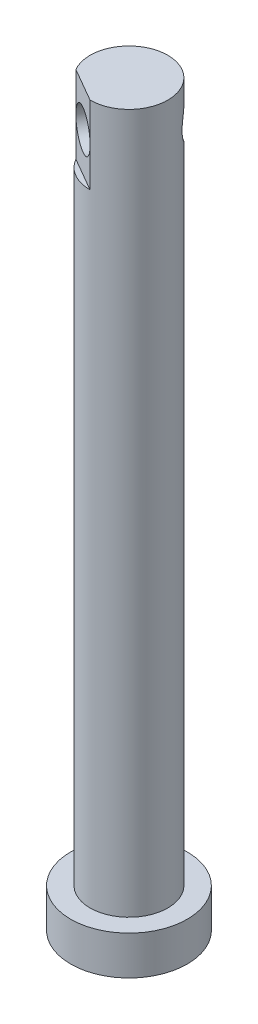
from build123d import *

# Parameters (mm, degrees)
SKETCH_1_R          = 7.5
EXTRUDE_1_DEPTH     = 5
SKETCH_2_R          = 5
EXTRUDE_2_DEPTH     = 90
CUT_EXTRUDE_1_DEPTH = 10
SKETCH_13_R         = 2.500883101
CUT_EXTRUDE_2_DEPTH = 10


with BuildPart() as part:
    # Эскиз1 → Бобышка-Вытянуть1 (new body)
    with BuildSketch(Plane(origin=(0, 0, 0), x_dir=(1, 0, 0), z_dir=(0, 1, 0))):
        with Locations((40.81014851, -30.211534636)):
            Circle(SKETCH_1_R)
    extrude(amount=EXTRUDE_1_DEPTH)

    # Эскиз2 → Бобышка-Вытянуть2 (add)
    with BuildSketch(Plane(origin=(0, 5, 0), x_dir=(1, 0, 0), z_dir=(0, 1, 0))):
        with Locations((40.81014851, -30.211534636)):
            Circle(SKETCH_2_R)
    extrude(amount=EXTRUDE_2_DEPTH)

    # Эскиз12 → Вырез-Вытянуть1 (cut)
    with BuildSketch(Plane(origin=(0, 95, 0), x_dir=(1, 0, 0), z_dir=(0, 1, 0))):
        Polygon((40.81014851, -35.211534636), (36.479002075, -32.709768123), (36.139784444, -33.297033651), (40.47093088, -35.798800164), align=None)
    extrude(amount=-CUT_EXTRUDE_1_DEPTH, mode=Mode.SUBTRACT)

    # Эскиз13 → Вырез-Вытянуть2 (cut)
    with BuildSketch(Plane(origin=(-5.040884978, 0, 8.726957886), x_dir=(0.865923408, 0, 0.50017662), z_dir=(-0.50017662, 0, 0.865923408))):
        with Locations((50.449566166, 90)):
            Circle(SKETCH_13_R)
    extrude(amount=-CUT_EXTRUDE_2_DEPTH, mode=Mode.SUBTRACT)


solid = part.part
